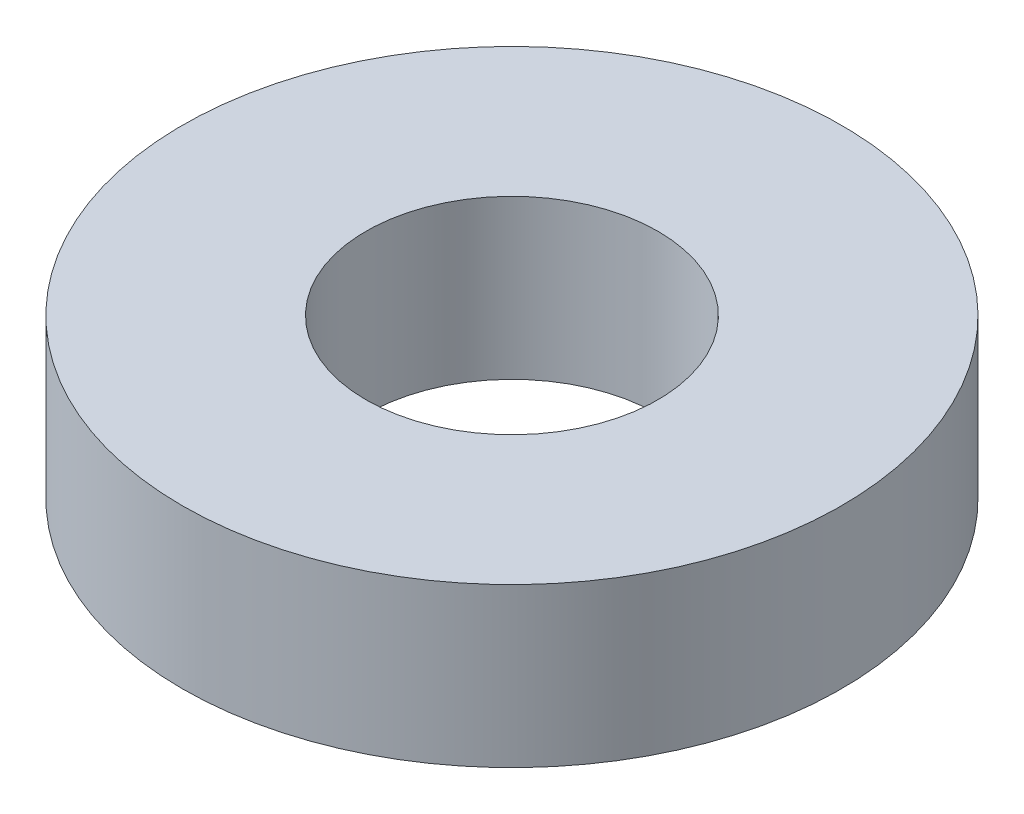
from build123d import *

# Parameters (mm, degrees)
SKETCH1_R           = 3.95
SKETCH1_R_2         = 1.75
BOSS_EXTRUDE1_DEPTH = 1.9


with BuildPart() as part:
    # Sketch1 → Boss-Extrude1 (new body)
    with BuildSketch(Plane(origin=(0, 0, 0), x_dir=(1, 0, 0), z_dir=(0, 1, 0))):
        Circle(SKETCH1_R)
        Circle(SKETCH1_R_2, mode=Mode.SUBTRACT)
    extrude(amount=BOSS_EXTRUDE1_DEPTH)


solid = part.part
